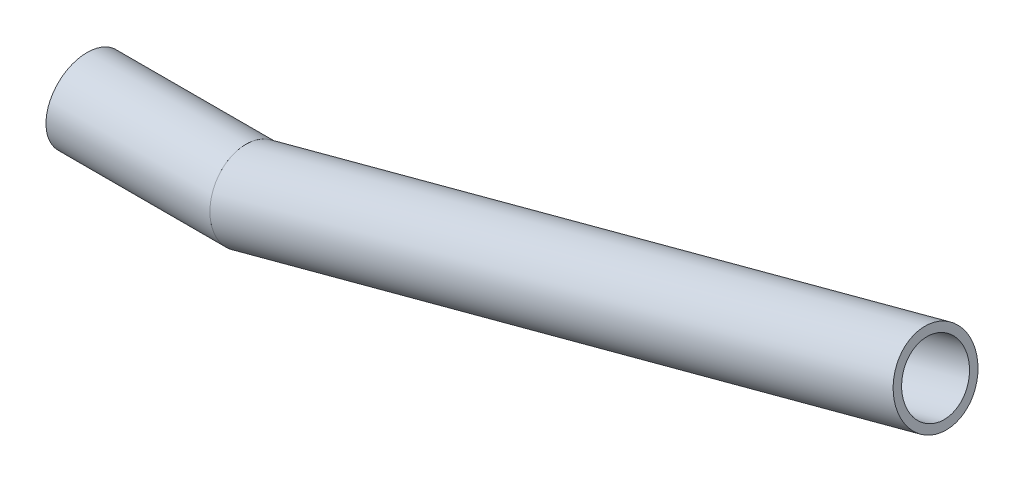
from build123d import *

# Parameters (mm, degrees)
SKETCH1_R                = 12.7
SKETCH1_R_2              = 10.16
TUBING_TUBING_1_DEPTH    = 54.164546295
SKETCH1_ON_SEGMENT_2_R   = 12.7
SKETCH1_ON_SEGMENT_2_R_2 = 10.16
TUBING_TUBING_1_2_DEPTH  = 222.312546295


with BuildPart() as part:
    # Sketch1 → Tubing TUBING(1) (new body)
    with BuildSketch(Plane(origin=(-107.318138062, 25.893490854, 0), x_dir=(0, 1, 0), z_dir=(1, 0, 0))):
        Circle(SKETCH1_R)
        Circle(SKETCH1_R_2, mode=Mode.SUBTRACT)
    extrude(amount=TUBING_TUBING_1_DEPTH)

    # Tubing TUBING(1) mitre 1
    split(bisect_by=Plane(origin=(-56.518138062, 25.893490854, 0), x_dir=(0.130526192, -0.991444861, 0), z_dir=(-0.991444861, -0.130526192, 0)), keep=Keep.TOP)


with BuildPart() as body_2:
    # Sketch1 on segment 2 (carried to segment 2) → Tubing TUBING_1 2 (new body)
    with BuildSketch(Plane(origin=(-59.768040222, 25.022682195, 0), x_dir=(-0.258819045, 0.965925826, 0), z_dir=(0.965925826, 0.258819045, 0))):
        Circle(SKETCH1_ON_SEGMENT_2_R)
        Circle(SKETCH1_ON_SEGMENT_2_R_2, mode=Mode.SUBTRACT)
    extrude(amount=TUBING_TUBING_1_2_DEPTH)

    # Tubing TUBING_1 2 mitre 1
    split(bisect_by=Plane(origin=(-56.518138062, 25.893490854, 0), x_dir=(-0.130526192, 0.991444861, 0), z_dir=(0.991444861, 0.130526192, 0)), keep=Keep.TOP)


solid = Compound([part.part, body_2.part])
